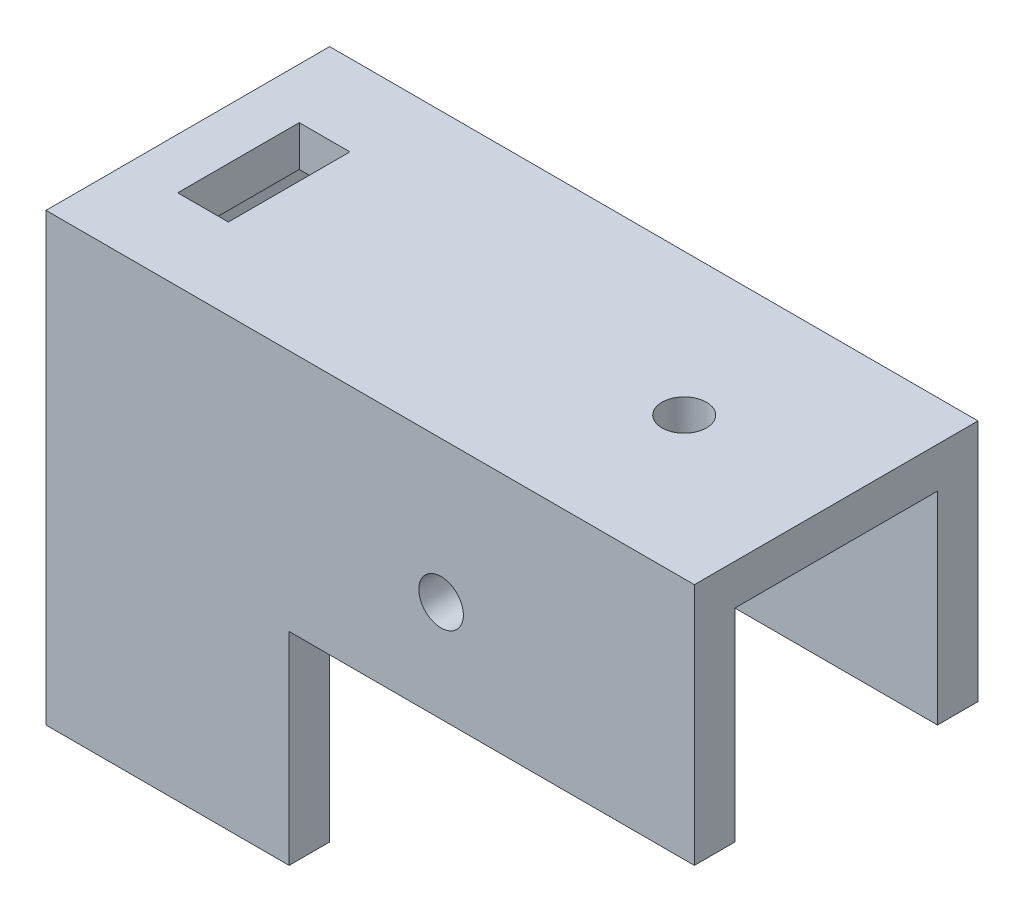
from build123d import *

# Parameters (mm, degrees)
BOSS_EXTRU_1_DEPTH      = 28
ENL_V_MAT_EXTRU_1_DEPTH = 40
ESQUISSE3_W             = 33
ESQUISSE3_H             = 20
ENL_V_MAT_EXTRU_2_DEPTH = 20
D_GAGEMENT_M41_D        = 4.4
D_GAGEMENT_M41_DEPTH    = 5
D_GAGEMENT_M42_D        = 4.4
D_GAGEMENT_M43_D        = 4.4
D_GAGEMENT_M43_DEPTH    = 5
ESQUISSE13_W            = 5
ESQUISSE13_H            = 12
ENL_V_MAT_EXTRU_4_DEPTH = 10


with BuildPart() as part:
    # Esquisse1 → Boss.-Extru.1 (new body)
    with BuildSketch(Plane.XY):
        Polygon((0, 0), (64, 0), (64, -24), (24, -24), (24, -44), (0, -44), align=None)
    extrude(amount=BOSS_EXTRU_1_DEPTH)

    # Esquisse2 → Enlèv. mat.-Extru.1 (cut)
    with BuildSketch(Plane.XZ.offset(44)):
        Polygon((24, 24), (17, 24), (17, 21.5), (11, 21.5), (11, 24), (4, 24), (4, 4), (11, 4), (11, 6.5), (17, 6.5), (17, 4), (24, 4), align=None)
    extrude(amount=-ENL_V_MAT_EXTRU_1_DEPTH, mode=Mode.SUBTRACT)

    # Esquisse3 → Enlèv. mat.-Extru.2 (cut)
    with BuildSketch(Plane.XZ.offset(24)):
        with Locations((47.5, 14)):
            Rectangle(ESQUISSE3_W, ESQUISSE3_H)
    extrude(amount=-ENL_V_MAT_EXTRU_2_DEPTH, mode=Mode.SUBTRACT)

    # Dégagement M41
    with Locations(Plane.ZY):
        with Locations((14, -15.5), (14, -30.5)):
            Hole(D_GAGEMENT_M41_D / 2, depth=D_GAGEMENT_M41_DEPTH)

    # Dégagement M42 (through all)
    with Locations(Plane.XY.offset(28)):
        with Locations((39, -14)):
            Hole(D_GAGEMENT_M42_D / 2)

    # Dégagement M43
    with Locations(Plane(origin=(0, 0, 0), x_dir=(1, 0, 0), z_dir=(0, 1, 0))):
        with Locations((49, -14)):
            Hole(D_GAGEMENT_M43_D / 2, depth=D_GAGEMENT_M43_DEPTH)

    # Esquisse13 → Enlèv. mat.-Extru.4 (cut)
    with BuildSketch(Plane(origin=(0, 0, 0), x_dir=(1, 0, 0), z_dir=(0, 1, 0))):
        with Locations((7.5, -14)):
            Rectangle(ESQUISSE13_W, ESQUISSE13_H)
    extrude(amount=-ENL_V_MAT_EXTRU_4_DEPTH, mode=Mode.SUBTRACT)


solid = part.part
